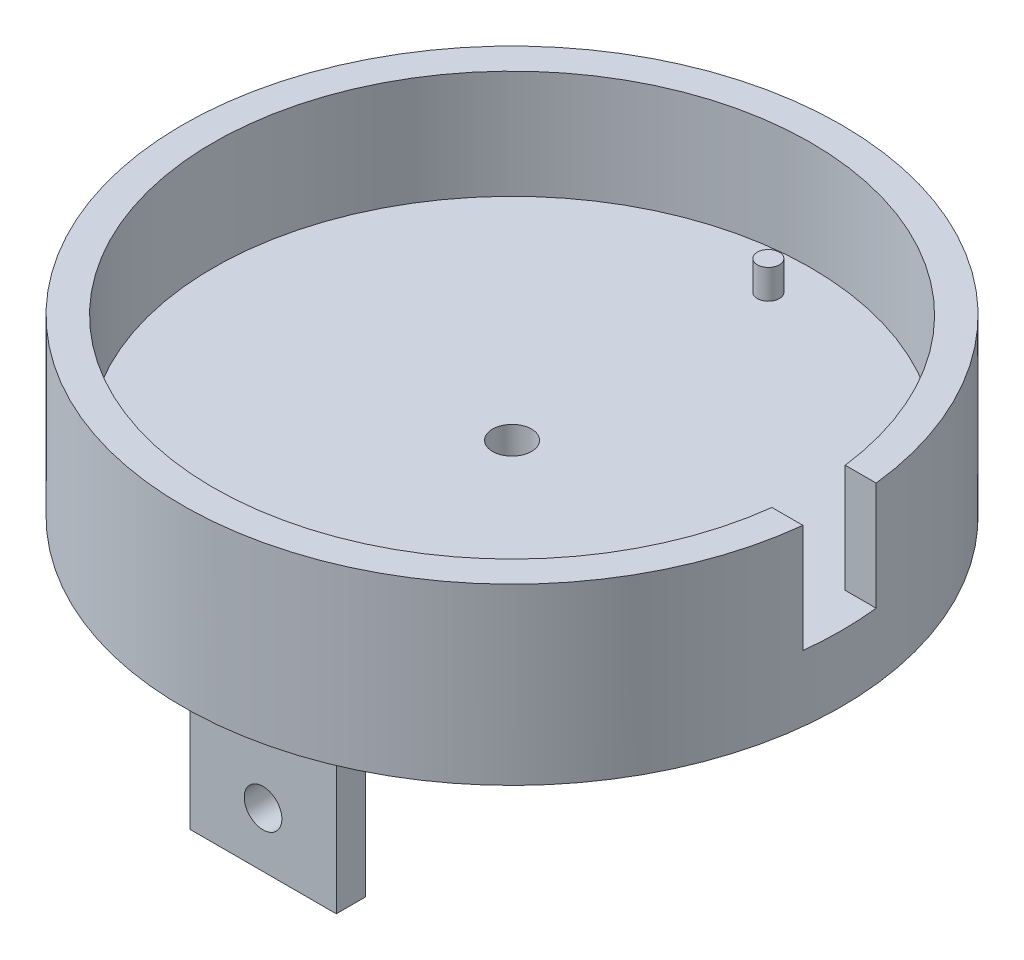
from build123d import *

# Parameters (mm, degrees)
REVOLVE1_ANGLE          = 360
CUT_EXTRUDE2_REACH      = 116.3
SKETCH4_W               = 12.7
SKETCH4_H               = 18.796
SKETCH5_R               = 3.3782
CUT_EXTRUDE3_DEPTH      = 31.226
SKETCH6_R               = 1.905
BOSS_EXTRUDE1_DEPTH     = 5.08
SKETCH7_W               = 25.4
SKETCH7_H               = 5.08
BOSS_EXTRUDE4_DEPTH     = 31.75
FILLET1_R               = 6.35
SKETCH8_R               = 3.2639
CUT_EXTRUDE4_DEPTH      = 14.97
CUT_EXTRUDE4_DEPTH_BACK = 101.33


with BuildPart() as part:
    # Sketch1 → Revolve1 (revolve, symmetric)
    with BuildSketch(Plane.XY) as revolve1_sk:
        Polygon((0, 0), (57.15, 0), (57.15, 30.226), (51.816, 30.226), (51.816, 11.43), (0, 11.43), align=None)
    revolve(axis=Axis((0, 0, 0), (0, 1, 0)), revolution_arc=REVOLVE1_ANGLE / 2)
    revolve(revolve1_sk.sketch, axis=Axis((0, 0, 0), (0, -1, 0)), revolution_arc=REVOLVE1_ANGLE / 2)

    # Sketch4 → Cut-Extrude2 (cut, up to next)
    with BuildSketch(Plane(origin=(57.15, 0, 0), x_dir=(0, 0, -1), z_dir=(1, 0, 0)), mode=Mode.PRIVATE) as cut_extrude2_sk1:
        with Locations((0, 20.828)):
            Rectangle(SKETCH4_W, SKETCH4_H)
    cut_extrude2_tool1 = extrude(cut_extrude2_sk1.sketch, amount=-CUT_EXTRUDE2_REACH, mode=Mode.PRIVATE) & part.part
    add(cut_extrude2_tool1.solids().sort_by_distance((57.15, 20.828, 0))[0], mode=Mode.SUBTRACT)

    # Sketch5 → Cut-Extrude3 (cut, through all)
    with BuildSketch(Plane.XZ):
        Circle(SKETCH5_R)
    extrude(amount=-CUT_EXTRUDE3_DEPTH, mode=Mode.SUBTRACT)

    # Sketch6 → Boss-Extrude1 (add)
    with BuildSketch(Plane(origin=(0, 11.43, 0), x_dir=(1, 0, 0), z_dir=(0, 1, 0))):
        with Locations((0, 44.45)):
            Circle(SKETCH6_R)
        with Locations((0, -44.45)):
            Circle(SKETCH6_R)
    extrude(amount=BOSS_EXTRUDE1_DEPTH)

    # Sketch7 → Boss-Extrude4 (add)
    with BuildSketch(Plane(origin=(0, 0, 0), x_dir=(1, 0, 0), z_dir=(0, 1, 0))):
        with Locations((0, -40.64)):
            Rectangle(SKETCH7_W, SKETCH7_H)
        with Locations((0, 40.64)):
            Rectangle(SKETCH7_W, SKETCH7_H)
    extrude(amount=-BOSS_EXTRUDE4_DEPTH)

    # Fillet1
    fillet1_edges = [part.edges().sort_by_distance(p)[0] for p in [
        (12.7, 0, 40.64),
        (-12.7, 0, 40.64),
        (0, 0, 43.18),
        (-12.7, 0, -40.64),
        (12.7, 0, -40.64),
        (0, 0, -43.18),
    ]]
    fillet(fillet1_edges, radius=FILLET1_R)

    # Sketch8 → Cut-Extrude4 (cut, two sides)
    with BuildSketch(Plane.XY.offset(43.18)) as cut_extrude4_sk:
        with Locations((0, -22.225)):
            Circle(SKETCH8_R)
    extrude(amount=CUT_EXTRUDE4_DEPTH, mode=Mode.SUBTRACT)
    extrude(cut_extrude4_sk.sketch, amount=-CUT_EXTRUDE4_DEPTH_BACK, mode=Mode.SUBTRACT)


solid = part.part
